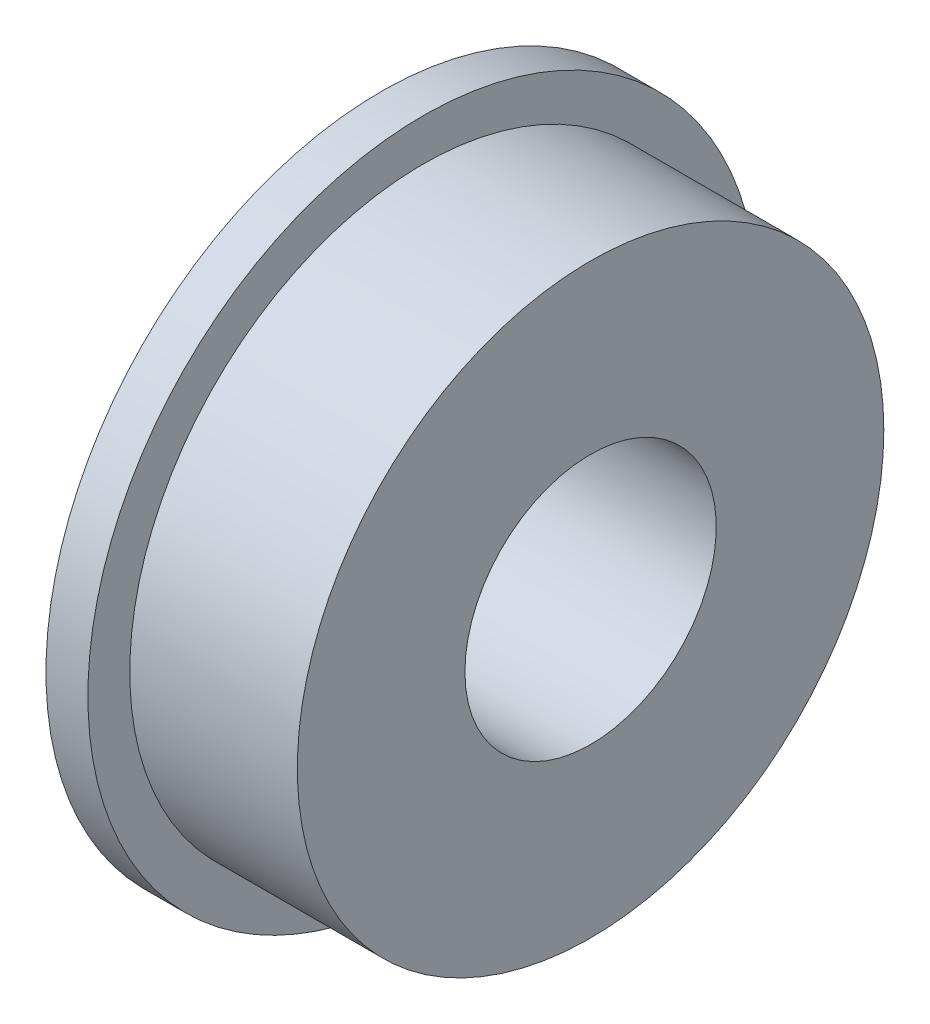
from build123d import *

# Parameters (mm, degrees)
SKETCH1_R           = 25.4
BOSS_EXTRUDE1_DEPTH = 3.175
SKETCH2_R           = 22.225
BOSS_EXTRUDE2_DEPTH = 12.7
SKETCH3_R           = 9.525
CUT_EXTRUDE1_DEPTH  = 16.875


with BuildPart() as part:
    # Sketch1 → Boss-Extrude1 (new body)
    with BuildSketch(Plane(origin=(0, 0, 0), x_dir=(0, 0, -1), z_dir=(1, 0, 0))):
        Circle(SKETCH1_R)
    extrude(amount=BOSS_EXTRUDE1_DEPTH)

    # Sketch2 → Boss-Extrude2 (add)
    with BuildSketch(Plane(origin=(3.175, 0, 0), x_dir=(0, 0, -1), z_dir=(1, 0, 0))):
        Circle(SKETCH2_R)
    extrude(amount=BOSS_EXTRUDE2_DEPTH)

    # Sketch3 → Cut-Extrude1 (cut, through all)
    with BuildSketch(Plane.ZY):
        Circle(SKETCH3_R)
    extrude(amount=-CUT_EXTRUDE1_DEPTH, mode=Mode.SUBTRACT)


solid = part.part
